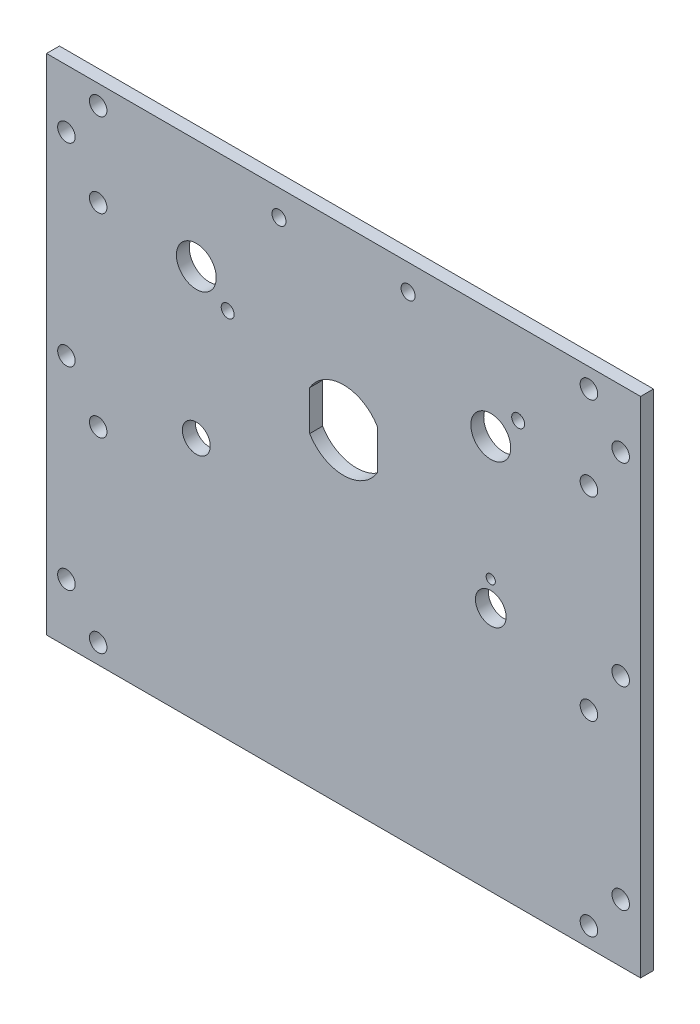
from build123d import *

# Parameters (mm, degrees)
SKETCH1_W                = 146.05
SKETCH1_H                = 123.825
BOSS_EXTRUDE1_DEPTH      = 3.175
F_6_CLEARANCE_HOLE1_D    = 4.3053
SKETCH4_R                = 4.9022
SKETCH4_R_2              = 3.7703125
SKETCH4_R_3              = 3.429
SKETCH4_R_4              = 1.125
SKETCH4_R_5              = 1.5875
SWITCH_MOUNT_HOLES_DEPTH = 4.175
F_4_CLEARANCE_HOLE1_D    = 3.4544


with BuildPart() as part:
    # Sketch1 → Boss-Extrude1 (new body)
    with BuildSketch(Plane.XY):
        with Locations((-73.025, 61.9125)):
            Rectangle(SKETCH1_W, SKETCH1_H)
    extrude(amount=-BOSS_EXTRUDE1_DEPTH)

    # #6 Clearance Hole1 (through all)
    with Locations(Plane(origin=(0, 0, -3.175), x_dir=(-1, 0, 0), z_dir=(0, 0, -1))):
        with Locations((12.7, 119.0625), (133.35, 119.0625), (141.1605, 109.5375), (133.35, 98.425), (141.1605, 61.9125), (133.35, 50.673), (133.35, 4.7625), (12.7, 4.7625), (12.7, 50.673), (12.7, 98.425), (4.8895, 109.5375), (141.1605, 14.2875), (4.8895, 14.2875), (4.8895, 61.9125)):
            Hole(F_6_CLEARANCE_HOLE1_D / 2)

    # Sketch4 → Switch Mount Holes (cut, through all)
    with BuildSketch(Plane(origin=(0, 0, -3.175), x_dir=(-1, 0, 0), z_dir=(0, 0, -1))):
        with Locations((36.83, 96.901)):
            Circle(SKETCH4_R)
        with Locations((36.83, 60.325)):
            Circle(SKETCH4_R_2)
        with Locations((109.22, 60.325)):
            Circle(SKETCH4_R_3)
        with Locations((109.22, 96.901)):
            Circle(SKETCH4_R)
        with Locations((36.830000027, 66.525)):
            Circle(SKETCH4_R_4)
        with Locations((101.514113129, 91.302345472)):
            Circle(SKETCH4_R_5)
        with Locations((30.094807909, 103.636192091)):
            Circle(SKETCH4_R_5)
        with BuildLine():
            Line((81.3435, 85.032269324), (81.3435, 75.241730676))
            ThreePointArc((81.3435, 75.241730676), (73.025, 70.485), (64.7065, 75.241730676))
            Line((64.7065, 75.241730676), (64.7065, 85.032269324))
            ThreePointArc((64.7065, 85.032269324), (73.025, 89.789), (81.3435, 85.032269324))
        make_face()
    extrude(amount=-SWITCH_MOUNT_HOLES_DEPTH, mode=Mode.SUBTRACT)

    # #4 Clearance Hole1 (through all)
    with Locations(Plane.XY):
        with Locations((-88.9, 117.475), (-57.15, 117.475)):
            Hole(F_4_CLEARANCE_HOLE1_D / 2)


solid = part.part
